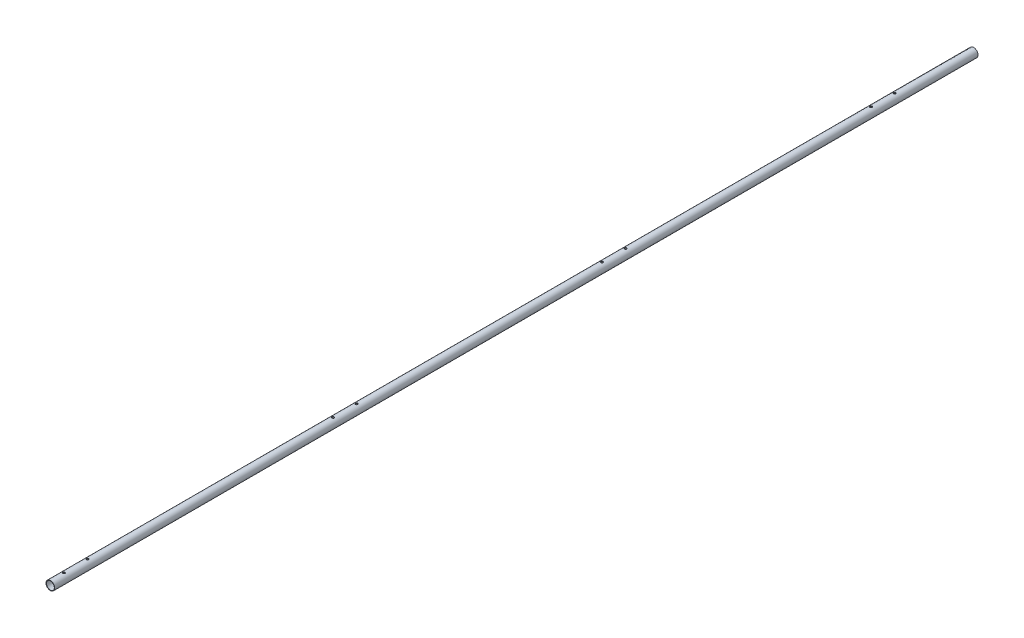
from build123d import *

# Parameters (mm, degrees)
SKETCH1_R                       = 10
SKETCH1_R_2                     = 9
EXTRUDE_THIN1_DEPTH             = 2114
F_10_CLEARANCE_HOLE1_AT_2_COUNT = 2
F_10_CLEARANCE_HOLE1_AT_2_PITCH = 54
LPATTERN1_COUNT                 = 4
LPATTERN1_PITCH                 = 616


with BuildPart() as part:
    # Sketch1 → Extrude-Thin1 (new body)
    with BuildSketch(Plane.XY):
        Circle(SKETCH1_R)
        Circle(SKETCH1_R_2, mode=Mode.SUBTRACT)
    extrude(amount=EXTRUDE_THIN1_DEPTH)

    # Sketch4 → #10 Clearance Hole1 (revolve, cut)
    with BuildSketch(Plane(origin=(0, 10, 181.1), x_dir=(0, 0, 1), z_dir=(1, 0, 0))):
        Polygon((0, 0), (0, 11.533816902), (2.5527, 10), (2.5527, 0), align=None)
    f_10_clearance_hole1 = revolve(axis=Axis((0, 16.35, 181.1), (0, -1, 0)), mode=Mode.SUBTRACT)

    # #10 Clearance Hole1 at 2: #10 Clearance Hole1 ×2
    with Locations(*[(0, 0, i * F_10_CLEARANCE_HOLE1_AT_2_PITCH) for i in range(1, F_10_CLEARANCE_HOLE1_AT_2_COUNT)]):
        add(f_10_clearance_hole1, mode=Mode.SUBTRACT)

    # LPattern1: #10 Clearance Hole1 ×4
    with Locations(*[(0, 0, i * LPATTERN1_PITCH) for i in range(1, LPATTERN1_COUNT)]):
        add(f_10_clearance_hole1, mode=Mode.SUBTRACT)

    # LPattern1 copy 1 sketch → LPattern1 copy 1 (revolve, cut)
    with BuildSketch(Plane(origin=(0, 10, 851.1), x_dir=(0, 0, 1), z_dir=(1, 0, 0))):
        Polygon((0, 0), (0, 11.533816902), (2.5527, 10), (2.5527, 0), align=None)
    revolve(axis=Axis((0, 16.35, 851.1), (0, -1, 0)), mode=Mode.SUBTRACT)

    # LPattern1 copy 2 sketch → LPattern1 copy 2 (revolve, cut)
    with BuildSketch(Plane(origin=(0, 10, 1467.1), x_dir=(0, 0, 1), z_dir=(1, 0, 0))):
        Polygon((0, 0), (0, 11.533816902), (2.5527, 10), (2.5527, 0), align=None)
    revolve(axis=Axis((0, 16.35, 1467.1), (0, -1, 0)), mode=Mode.SUBTRACT)

    # LPattern1 copy 3 sketch → LPattern1 copy 3 (revolve, cut)
    with BuildSketch(Plane(origin=(0, 10, 2083.1), x_dir=(0, 0, 1), z_dir=(1, 0, 0))):
        Polygon((0, 0), (0, 11.533816902), (2.5527, 10), (2.5527, 0), align=None)
    revolve(axis=Axis((0, 16.35, 2083.1), (0, -1, 0)), mode=Mode.SUBTRACT)


solid = part.part
